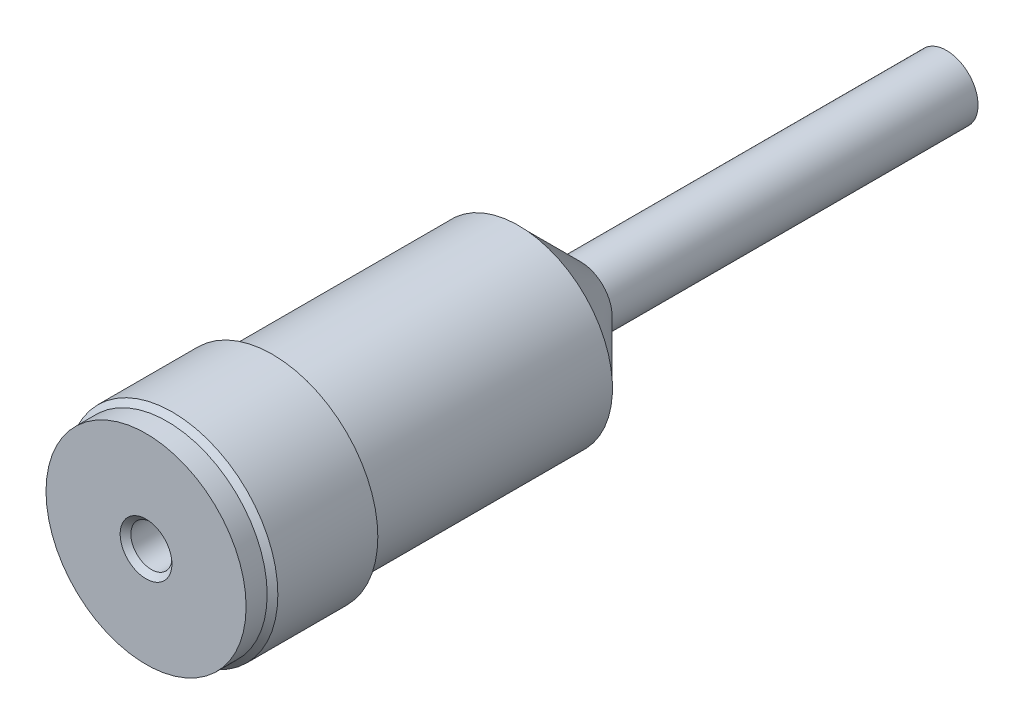
from build123d import *

# Parameters (mm, degrees)
SKETCH1_R           = 5.0038
EXTRUDE1_DEPTH      = 37
SKETCH2_R           = 0.974600032
EXTRUDE2_DEPTH      = 7.5
SKETCH3_OUTSIDE_W   = 19.93
SKETCH3_OUTSIDE_H   = 19.93
SKETCH3_OUTSIDE_R   = 1.5
EXTRUDE3_DEPTH      = 20.32
SKETCH5_R           = 0.635
EXTRUDE4_DEPTH      = 20.32
CHAMFER2_SIZE       = 0.254
SKETCH6_W           = 0.539999936
SKETCH6_H           = 11.68
CHAMFER3_SIZE       = 2.9464
SKETCH8_R           = 4.7498
SKETCH8_R_2         = 0.974600032
BOSS_EXTRUDE1_DEPTH = 1
CHAMFER4_SIZE       = 0.254


with BuildPart() as part:
    # Sketch1 → Extrude1 (new body)
    with BuildSketch(Plane.XY):
        Circle(SKETCH1_R)
    extrude(amount=-EXTRUDE1_DEPTH)

    # Sketch2 → Extrude2 (cut)
    with BuildSketch(Plane.XY):
        Circle(SKETCH2_R)
    extrude(amount=-EXTRUDE2_DEPTH, mode=Mode.SUBTRACT)

    # Sketch3 outside → Extrude3 (cut)
    with BuildSketch(Plane(origin=(0, 0, -37), x_dir=(-1, 0, 0), z_dir=(0, 0, -1))):
        Rectangle(SKETCH3_OUTSIDE_W, SKETCH3_OUTSIDE_H)
        Circle(SKETCH3_OUTSIDE_R, mode=Mode.SUBTRACT)
    extrude(amount=-EXTRUDE3_DEPTH, mode=Mode.SUBTRACT)

    # Sketch5 → Extrude4 (cut)
    with BuildSketch(Plane(origin=(0, 0, 0), x_dir=(0, 0, -1), z_dir=(1, 0, 0))):
        with Locations((7, 0)):
            Circle(SKETCH5_R)
    extrude(amount=-EXTRUDE4_DEPTH, mode=Mode.SUBTRACT)

    # Chamfer2
    chamfer2_edges = [part.edges().sort_by_distance(p)[0] for p in [
        (-5.0038, 0, 0),
    ]]
    chamfer(chamfer2_edges, length=CHAMFER2_SIZE)

    # Sketch6 → Cut-Revolve1 (revolve, cut)
    with BuildSketch(Plane(origin=(0, 0, 0), x_dir=(1, 0, 0), z_dir=(0, 1, 0))):
        with Locations((-4.733800032, 10.84)):
            Rectangle(SKETCH6_W, SKETCH6_H)
    revolve(axis=Axis((0, 0, -37), (0, 0, 1)), mode=Mode.SUBTRACT)

    # Chamfer3
    chamfer3_edges = [part.edges().sort_by_distance(p)[0] for p in [
        (1.5, 0, -16.68),
    ]]
    chamfer(chamfer3_edges, length=CHAMFER3_SIZE)

    # Sketch8 → Boss-Extrude1 (add)
    with BuildSketch(Plane.XY):
        Circle(SKETCH8_R)
        Circle(SKETCH8_R_2, mode=Mode.SUBTRACT)
    extrude(amount=BOSS_EXTRUDE1_DEPTH)

    # Chamfer4
    chamfer4_edges = [part.edges().sort_by_distance(p)[0] for p in [
        (-0.974600032, 0, 1),
    ]]
    chamfer(chamfer4_edges, length=CHAMFER4_SIZE)


solid = part.part
